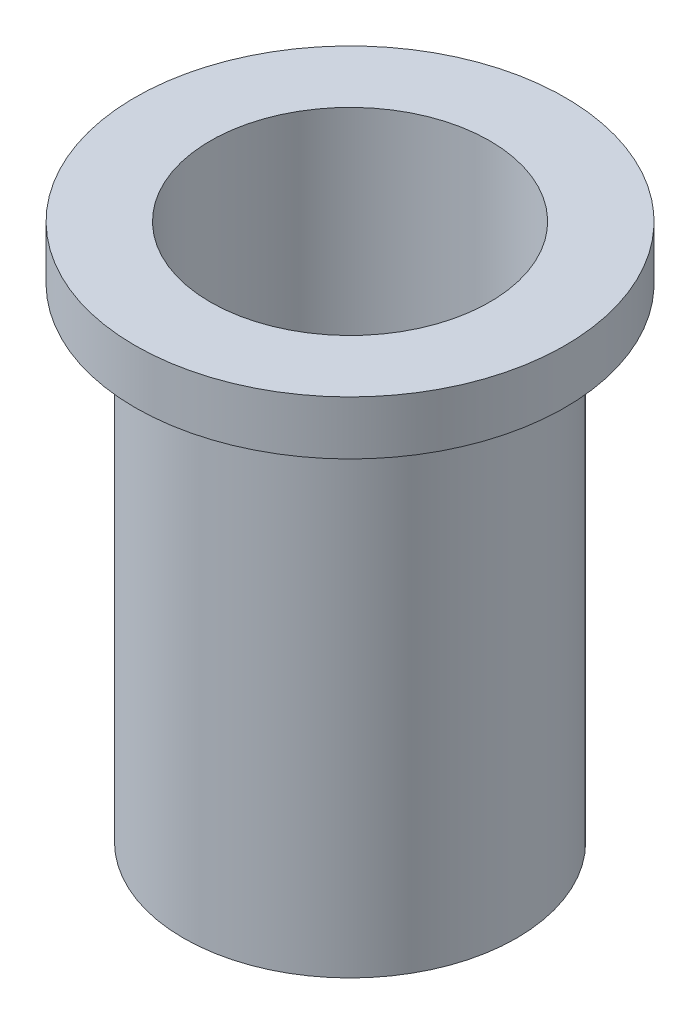
from build123d import *

# Parameters (mm, degrees)
SKETCH1_R           = 7.874
SKETCH1_R_2         = 6.604
BOSS_EXTRUDE1_DEPTH = 25.4
SKETCH2_R           = 10.16
SKETCH2_R_2         = 7.62
EXTRUDE_THIN1_DEPTH = 2.54


with BuildPart() as part:
    # Sketch1 → Boss-Extrude1 (new body)
    with BuildSketch(Plane(origin=(0, 0, 0), x_dir=(1, 0, 0), z_dir=(0, 1, 0))):
        Circle(SKETCH1_R)
        Circle(SKETCH1_R_2, mode=Mode.SUBTRACT)
    extrude(amount=BOSS_EXTRUDE1_DEPTH)

    # Sketch2 → Extrude-Thin1 (add)
    with BuildSketch(Plane(origin=(0, 25.4, 0), x_dir=(1, 0, 0), z_dir=(0, 1, 0))):
        Circle(SKETCH2_R)
        Circle(SKETCH2_R_2, mode=Mode.SUBTRACT)
    extrude(amount=-EXTRUDE_THIN1_DEPTH)


solid = part.part
